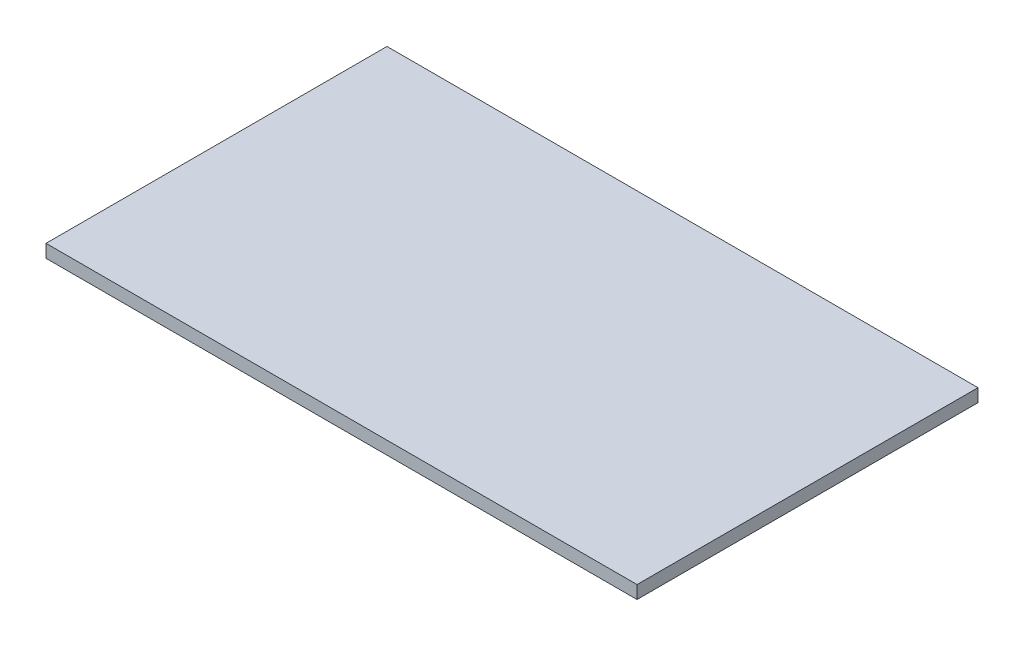
from build123d import *

# Parameters (mm, degrees)
SKETCH1_W           = 260
SKETCH1_H           = 150
BOSS_EXTRUDE1_DEPTH = 5.715


with BuildPart() as part:
    # Sketch1 → Boss-Extrude1 (new body)
    with BuildSketch(Plane(origin=(0, 0, 0), x_dir=(1, 0, 0), z_dir=(0, 1, 0))):
        with Locations((130, 75)):
            Rectangle(SKETCH1_W, SKETCH1_H)
    extrude(amount=BOSS_EXTRUDE1_DEPTH)


solid = part.part
